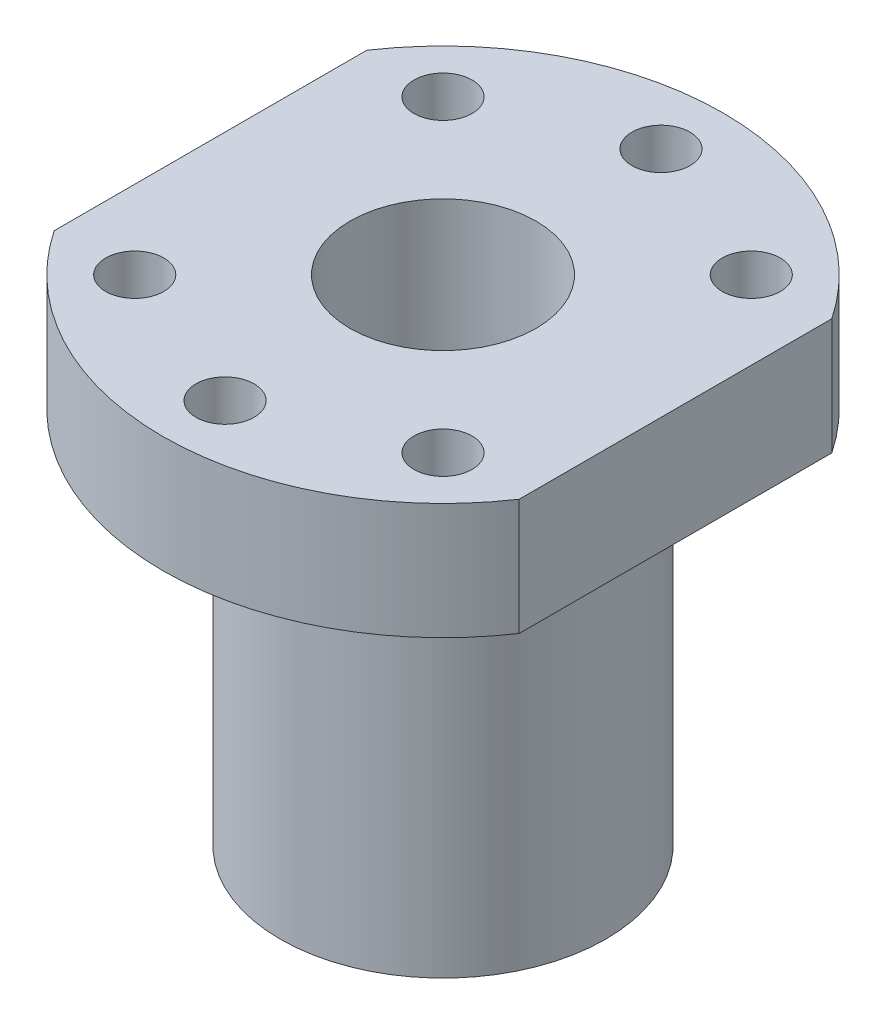
from build123d import *

# Parameters (mm, degrees)
SKETCH1_R           = 8
BOSS_EXTRUDE1_DEPTH = 10
BOSS_EXTRUDE2_START = -32.5
SKETCH1_3_R         = 14
SKETCH1_3_R_2       = 8
BOSS_EXTRUDE2_DEPTH = 32.5
SKETCH2_R           = 2.5
CUT_EXTRUDE1_DEPTH  = 32.5


with BuildPart() as part:
    # Sketch1 → Boss-Extrude1 (new body)
    with BuildSketch(Plane(origin=(0, 0, 0), x_dir=(1, 0, 0), z_dir=(0, 1, 0))):
        with BuildLine():
            ThreePointArc((20, 13.446560899), (0, 24.1), (-20, 13.446560899))
            Line((-20, 13.446560899), (-20, -13.446560899))
            ThreePointArc((-20, -13.446560899), (0, -24.1), (20, -13.446560899))
            Line((20, -13.446560899), (20, 13.446560899))
        make_face()
        Circle(SKETCH1_R, mode=Mode.SUBTRACT)
    extrude(amount=BOSS_EXTRUDE1_DEPTH)

    # Sketch1_3 → Boss-Extrude2 (add)
    with BuildSketch(Plane(origin=(0, 0, 0), x_dir=(1, 0, 0), z_dir=(0, 1, 0)).offset(BOSS_EXTRUDE2_START)):
        Circle(SKETCH1_3_R)
        Circle(SKETCH1_3_R_2, mode=Mode.SUBTRACT)
    extrude(amount=BOSS_EXTRUDE2_DEPTH)

    # Sketch2 → Cut-Extrude1 (cut)
    with BuildSketch(Plane(origin=(0, 10, 0), x_dir=(1, 0, 0), z_dir=(0, 1, 0))):
        with Locations((0, -18.75)):
            Circle(SKETCH2_R)
        with Locations((-13.258252147, -13.258252147)):
            Circle(SKETCH2_R)
        with Locations((-13.258252147, 13.258252147)):
            Circle(SKETCH2_R)
        with Locations((0, 18.75)):
            Circle(SKETCH2_R)
        with Locations((13.258252147, 13.258252147)):
            Circle(SKETCH2_R)
        with Locations((13.258252147, -13.258252147)):
            Circle(SKETCH2_R)
    extrude(amount=-CUT_EXTRUDE1_DEPTH, mode=Mode.SUBTRACT)


solid = part.part
